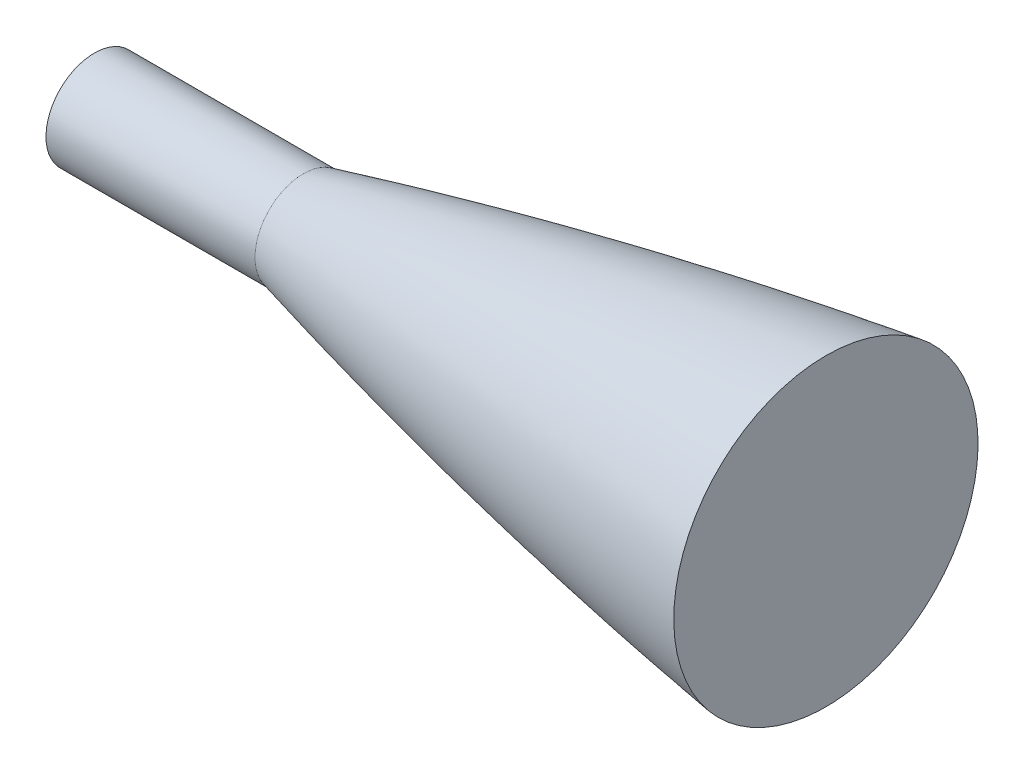
from build123d import *

# Parameters (mm, degrees)
SKETCH2_R           = 49.784
BOSS_EXTRUDE1_DEPTH = 203.2
SKETCH3_R           = 11.74839717
BOSS_EXTRUDE2_DEPTH = 50.8
SKETCH4_R           = 54.60446946
CUT_EXTRUDE1_DEPTH  = 382


with BuildPart() as part:
    # Sketch1 → Revolve1 (revolve)
    with BuildSketch(Plane.XY):
        with BuildLine():
            Line((304.8, 49.784), (304.8, 0))
            Line((304.8, 0), (0, 0))
            Line((0, 0), (0, 11.748397173))
            add(Edge.make_bspline(
                [(0, 11.748397173), (0.424160675, 11.855932678), (1.277768006, 12.07173392), (3.085410505, 12.527272667), (5.106222596, 13.032281093), (7.110128552, 13.529344024), (9.159948224, 14.034387922), (11.195444228, 14.532141119), (13.233412884, 15.026861964), (15.805049223, 15.64653599), (18.91026091, 16.387291474), (22.550652523, 17.244690048), (26.727238439, 18.213147263), (31.952168035, 19.405675489), (42.412897925, 21.742539102), (62.333903875, 25.976370199), (110.770450737, 35.225121195), (160.70732909, 42.159920913), (207.702302928, 46.434962608), (245.168015054, 48.368183749), (253.734807707, 48.740972714), (260.161369668, 48.98354131), (264.446272339, 49.130442523), (268.731666265, 49.262530797), (273.017475857, 49.379804553), (277.303691578, 49.48226239), (281.590188304, 49.569903083), (285.329649653, 49.633426545), (288.521672796, 49.67849525), (291.166731437, 49.70980578), (293.263778354, 49.731088433), (295.359186858, 49.74882407), (297.470177021, 49.76301264), (299.535126271, 49.773654103), (301.617177871, 49.780748429), (303.482211221, 49.783408805), (304.362420109, 49.784), (304.8, 49.784)],
                knots=[0.082917815, 0.082917815, 0.082917815, 0.082917815, 0.082917815, 0.088601511, 0.094285207, 0.099968902, 0.105652598, 0.111336294, 0.11701999, 0.122703686, 0.128387381, 0.140005218, 0.151623054, 0.16324089, 0.174858727, 0.198094396, 0.267801409, 0.383979763, 0.709279153, 0.744132659, 0.778986165, 0.790604, 0.802221836, 0.813839671, 0.825457507, 0.837075342, 0.848693177, 0.860311013, 0.871928848, 0.877612544, 0.883296239, 0.888979935, 0.89466363, 0.900347326, 0.906031021, 0.911714717, 0.917398412, 0.917398412, 0.917398412, 0.917398412, 0.917398412], degree=4))
        make_face()
    revolve(axis=Axis((304.8, 0, 0), (-1, 0, 0)))

    # Sketch2 → Boss-Extrude1 (add)
    with BuildSketch(Plane(origin=(304.8, 0, 0), x_dir=(0, 0, -1), z_dir=(1, 0, 0))):
        Circle(SKETCH2_R)
    extrude(amount=BOSS_EXTRUDE1_DEPTH)

    # Sketch3 → Boss-Extrude2 (add)
    with BuildSketch(Plane.ZY):
        Circle(SKETCH3_R)
    extrude(amount=BOSS_EXTRUDE2_DEPTH)

    # Sketch4 → Cut-Extrude1 (cut, through all)
    with BuildSketch(Plane(origin=(127, 0, 0), x_dir=(0, 0, -1), z_dir=(1, 0, 0))):
        Circle(SKETCH4_R)
    extrude(amount=CUT_EXTRUDE1_DEPTH, mode=Mode.SUBTRACT)


solid = part.part
